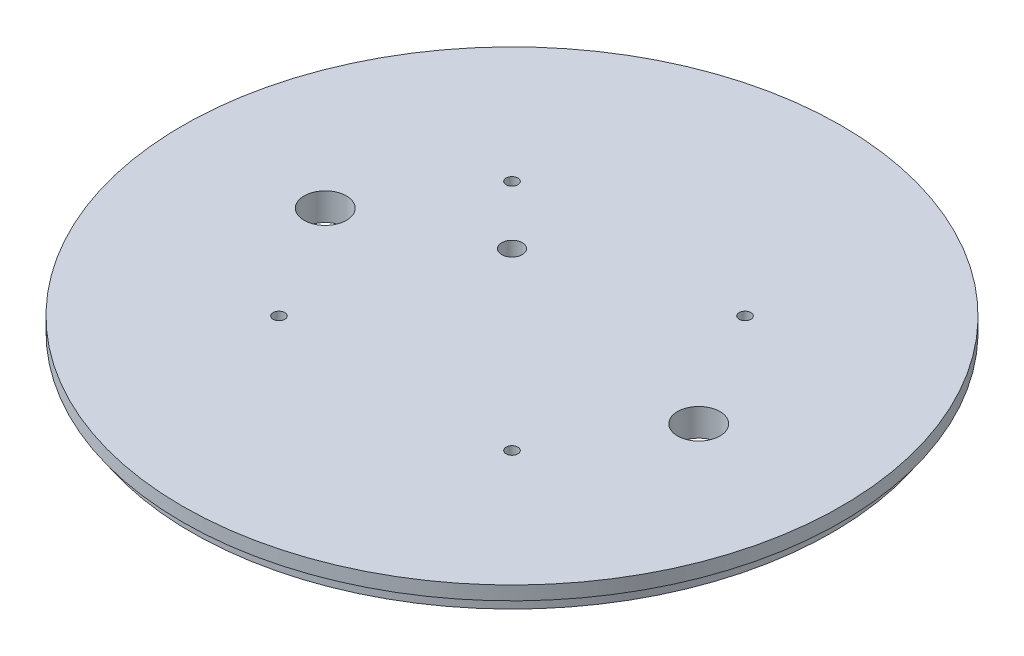
from build123d import *

# Parameters (mm, degrees)
SKETCH1_R           = 76.2
SKETCH1_R_2         = 1.3589
SKETCH1_R_3         = 4.9022
SKETCH1_R_4         = 2.38125
BOSS_EXTRUDE1_DEPTH = 6.35
SKETCH2_R           = 76.2
SKETCH2_R_2         = 74.041
CUT_EXTRUDE1_DEPTH  = 3.175
CUT_EXTRUDE2_START  = -3.175
CUT_EXTRUDE2_DEPTH  = 3.556


with BuildPart() as part:
    # Sketch1 → Boss-Extrude1 (new body)
    with BuildSketch(Plane(origin=(0, 0, 0), x_dir=(1, 0, 0), z_dir=(0, 1, 0))):
        Circle(SKETCH1_R)
        with Locations((26.940768363, 26.940768363)):
            Circle(SKETCH1_R_2, mode=Mode.SUBTRACT)
        with Locations((26.940768363, -26.940768363)):
            Circle(SKETCH1_R_2, mode=Mode.SUBTRACT)
        with Locations((-26.940768363, 26.940768363)):
            Circle(SKETCH1_R_2, mode=Mode.SUBTRACT)
        with Locations((43.18, 0)):
            Circle(SKETCH1_R_3, mode=Mode.SUBTRACT)
        with Locations((-43.18, 0)):
            Circle(SKETCH1_R_3, mode=Mode.SUBTRACT)
        with Locations((-13.470384182, 13.470384182)):
            Circle(SKETCH1_R_4, mode=Mode.SUBTRACT)
        with Locations((-26.940768363, -26.940768363)):
            Circle(SKETCH1_R_2, mode=Mode.SUBTRACT)
    extrude(amount=BOSS_EXTRUDE1_DEPTH)

    # Sketch2 → Cut-Extrude1 (cut)
    with BuildSketch(Plane.XZ):
        Circle(SKETCH2_R)
        Circle(SKETCH2_R_2, mode=Mode.SUBTRACT)
    extrude(amount=-CUT_EXTRUDE1_DEPTH, mode=Mode.SUBTRACT)

    # Sketch3 → Cut-Extrude2 (cut)
    with BuildSketch(Plane(origin=(0, 6.35, 0), x_dir=(1, 0, 0), z_dir=(0, 1, 0)).offset(CUT_EXTRUDE2_START)):
        with BuildLine():
            Line((3.2385, 34.798), (3.2385, 13.97))
            ThreePointArc((3.2385, 13.97), (0, 10.7315), (-3.2385, 13.97))
            Line((-3.2385, 13.97), (-3.2385, 34.798))
            ThreePointArc((-3.2385, 34.798), (0, 38.0365), (3.2385, 34.798))
        make_face()
        with BuildLine():
            Line((3.2385, -34.798), (3.2385, -13.97))
            ThreePointArc((3.2385, -13.97), (0, -10.7315), (-3.2385, -13.97))
            Line((-3.2385, -13.97), (-3.2385, -34.798))
            ThreePointArc((-3.2385, -34.798), (0, -38.0365), (3.2385, -34.798))
        make_face()
    extrude(amount=-CUT_EXTRUDE2_DEPTH, mode=Mode.SUBTRACT)


solid = part.part
